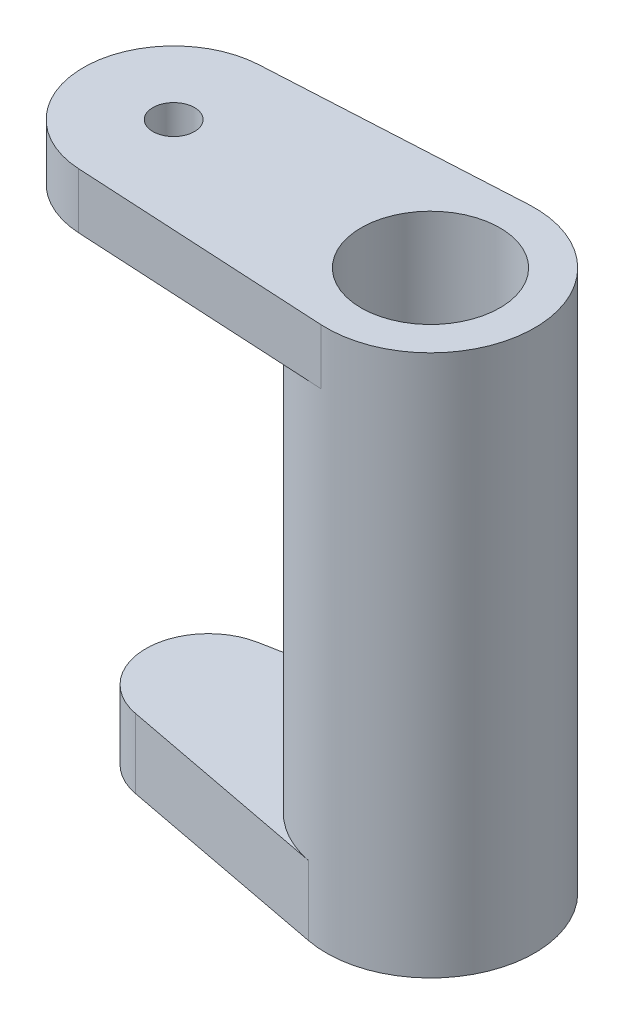
from build123d import *

# Parameters (mm, degrees)
CROQUIS1_R              = 7.5
SALIENTE_EXTRUIR1_DEPTH = 30
SALIENTE_EXTRUIR2_DEPTH = 4
SALIENTE_EXTRUIR3_DEPTH = 5
CROQUIS4_R              = 1.5
CORTAR_EXTRUIR1_DEPTH   = 5
CROQUIS5_R              = 5
CORTAR_EXTRUIR2_DEPTH   = 57.644348631


with BuildPart() as part:
    # Croquis1 → Saliente-Extruir1 (new body)
    with BuildSketch(Plane(origin=(0, 0, 0), x_dir=(1, 0, 0), z_dir=(0, 1, 0))):
        with Locations(Location((-15.184301915, -1.03253253, 0), (0, 0, 270))):
            Circle(CROQUIS1_R)
    extrude(amount=SALIENTE_EXTRUIR1_DEPTH)

    # Croquis2 → Saliente-Extruir2 (add)
    with BuildSketch(Plane(origin=(0, 30, 0), x_dir=(1, 0, 0), z_dir=(0, 1, 0))):
        with BuildLine():
            Line((-15.589707321, -8.521567612), (-34.035653267, -7.523029601))
            ThreePointArc((-34.035653267, -7.523029601), (-40.184301915, -1.03253253), (-34.035653267, 5.457964541))
            Line((-34.035653267, 5.457964541), (-15.589707321, 6.456502552))
            ThreePointArc((-15.589707321, 6.456502552), (-7.684301915, -1.03253253), (-15.589707321, -8.521567612))
        make_face()
    extrude(amount=SALIENTE_EXTRUIR2_DEPTH)

    # Croquis3 → Saliente-Extruir3 (add)
    with BuildSketch(Plane(origin=(0, 0, 0), x_dir=(-1, 0, 0), z_dir=(0, -1, 0))):
        with BuildLine():
            Line((32.028051915, -5.452723243), (16.590551915, -8.399517052))
            ThreePointArc((16.590551915, -8.399517052), (7.684301915, -1.03253253), (16.590551915, 6.334451991))
            Line((16.590551915, 6.334451991), (32.028051915, 3.387658183))
            ThreePointArc((32.028051915, 3.387658183), (35.684301915, -1.03253253), (32.028051915, -5.452723243))
        make_face()
    extrude(amount=SALIENTE_EXTRUIR3_DEPTH)

    # Croquis4 → Cortar-Extruir1 (cut)
    with BuildSketch(Plane(origin=(0, 34, 0), x_dir=(1, 0, 0), z_dir=(0, 1, 0))):
        with Locations(Location((-33.684301915, -1.03253253, 0), (0, 0, 270))):
            Circle(CROQUIS4_R)
    extrude(amount=-CORTAR_EXTRUIR1_DEPTH, mode=Mode.SUBTRACT)

    # Croquis5 → Cortar-Extruir2 (cut, through all)
    with BuildSketch(Plane(origin=(0, 34, 0), x_dir=(1, 0, 0), z_dir=(0, 1, 0))):
        with Locations(Location((-15.184301915, -1.03253253, 0), (0, 0, 270))):
            Circle(CROQUIS5_R)
    extrude(amount=-CORTAR_EXTRUIR2_DEPTH, mode=Mode.SUBTRACT)


solid = part.part
